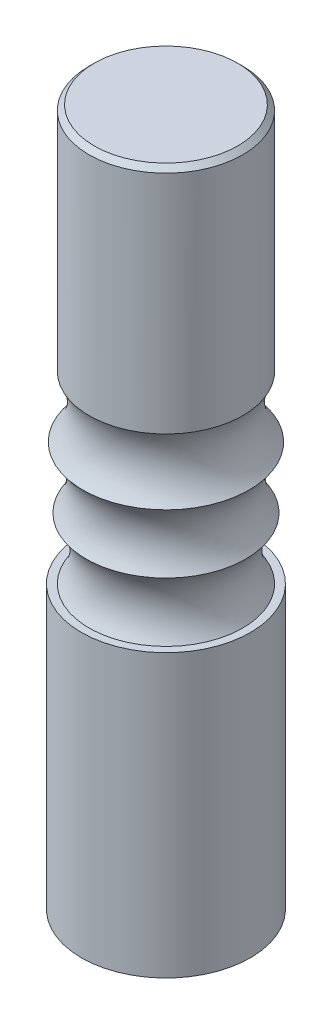
from build123d import *

# Parameters (mm, degrees)
ESQUISSE1_R        = 16.5
BOSS_EXTRU_1_DEPTH = 55
CHANFREIN1_SIZE    = 1


with BuildPart() as part:
    # Esquisse1 → Boss.-Extru.1 (new body)
    with BuildSketch(Plane(origin=(0, 0, 0), x_dir=(1, 0, 0), z_dir=(0, 1, 0))):
        with Locations(Location((0, 0, 0), (0, 0, 270))):  # turned: the seam where the file's is
            Circle(ESQUISSE1_R)
    extrude(amount=BOSS_EXTRU_1_DEPTH)

    # Esquisse4 → Révolution1 (revolve)
    with BuildSketch(Plane.XY, mode=Mode.PRIVATE) as r_volution1_sk:
        with BuildLine():
            Line((0, 55), (15, 55))
            ThreePointArc((15, 55), (13.247417463, 61.097125593), (15.610891732, 66.984440383))
            ThreePointArc((15.610891732, 66.984440383), (13.732283635, 73.092812528), (16.248093706, 78.967510676))
            ThreePointArc((16.248093706, 78.967510676), (13.634893892, 84.726953942), (15, 90.902428443))
            Line((15, 90.902428443), (15, 136))
            Line((15, 136), (0, 136))
            Line((0, 136), (0, 55))
        make_face()
    revolve(r_volution1_sk.sketch.rotate(Axis((0, 55, 0), (0, 1, 0)), 90), axis=Axis((0, 55, 0), (0, 1, 0)))  # turned: the seam where the file's is

    # Chanfrein1
    chanfrein1_edges = [part.edges().sort_by_distance(p)[0] for p in [
        (0, 136, 15),
    ]]
    chamfer(chanfrein1_edges, length=CHANFREIN1_SIZE)


solid = part.part
